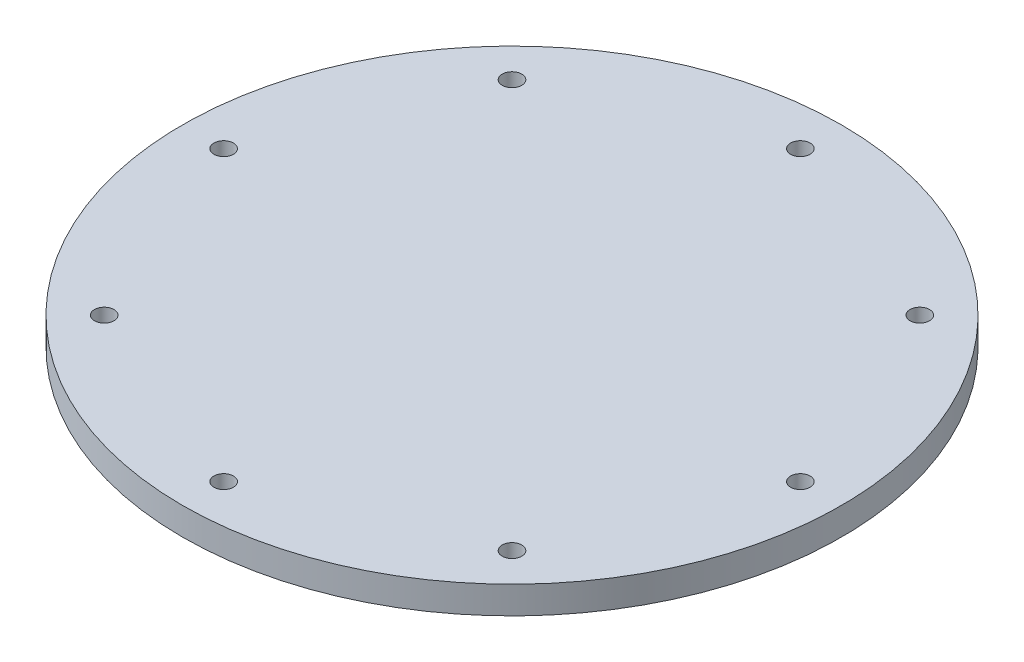
from build123d import *

# Parameters (mm, degrees)
SKETCH1_R                 = 38.1
BOSS_EXTRUDE1_DEPTH       = 3.175
TAP_DRILL_FOR_4_40_TAP1_D = 2.2606
CIRPATTERN1_COUNT         = 8


with BuildPart() as part:
    # Sketch1 → Boss-Extrude1 (new body)
    with BuildSketch(Plane(origin=(0, 0, 0), x_dir=(1, 0, 0), z_dir=(0, 1, 0))):
        Circle(SKETCH1_R)
    extrude(amount=BOSS_EXTRUDE1_DEPTH)

    # Tap Drill for #4-40 Tap1 (through all)
    with Locations(Plane(origin=(0, 0, 0), x_dir=(-1, 0, 0), z_dir=(0, -1, 0))):
        with Locations((0, -33.3375)):
            tap_drill_for_4_40_tap1 = Hole(TAP_DRILL_FOR_4_40_TAP1_D / 2)

    # CirPattern1: Tap Drill for #4-40 Tap1 ×8 about axis
    cirpattern1_axis = Axis((0, 0, 0), (0, 1, 0))
    for i in range(1, CIRPATTERN1_COUNT):
        add(tap_drill_for_4_40_tap1.rotate(cirpattern1_axis, i * 360 / CIRPATTERN1_COUNT), mode=Mode.SUBTRACT)


solid = part.part
